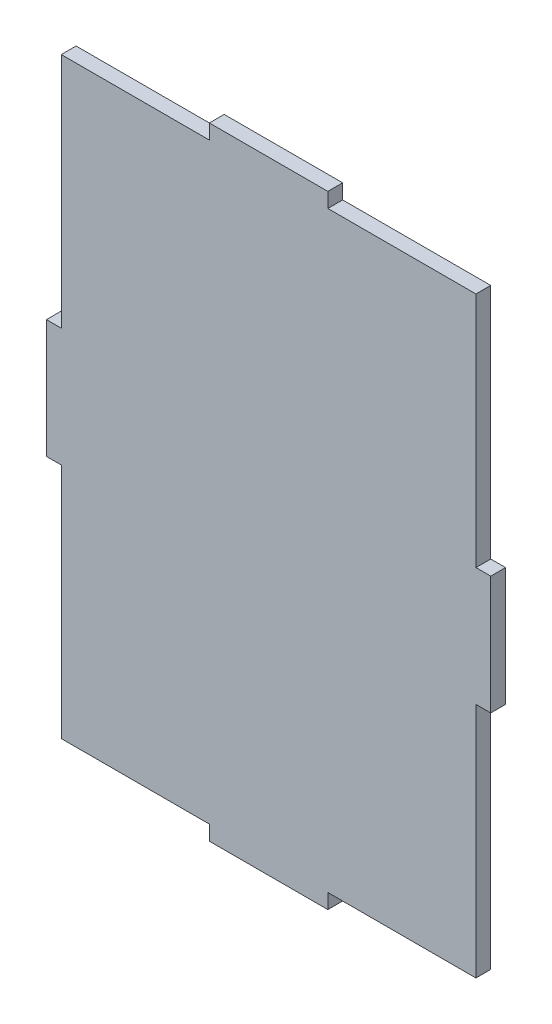
from build123d import *

# Parameters (mm, degrees)
SALIENTE_EXTRUIR1_DEPTH = 5


with BuildPart() as part:
    # Croquis1 → Saliente-Extruir1 (new body)
    with BuildSketch(Plane.XY):
        Polygon((-20, 100), (-70, 100), (-70, 20), (-75, 20), (-75, -20), (-70, -20), (-70, -100), (-20, -100), (-20, -105), (20, -105), (20, -100), (70, -100), (70, -20), (75, -20), (75, 20), (70, 20), (70, 100), (20, 100), (20, 105), (-20, 105), align=None)
    extrude(amount=SALIENTE_EXTRUIR1_DEPTH)


solid = part.part
